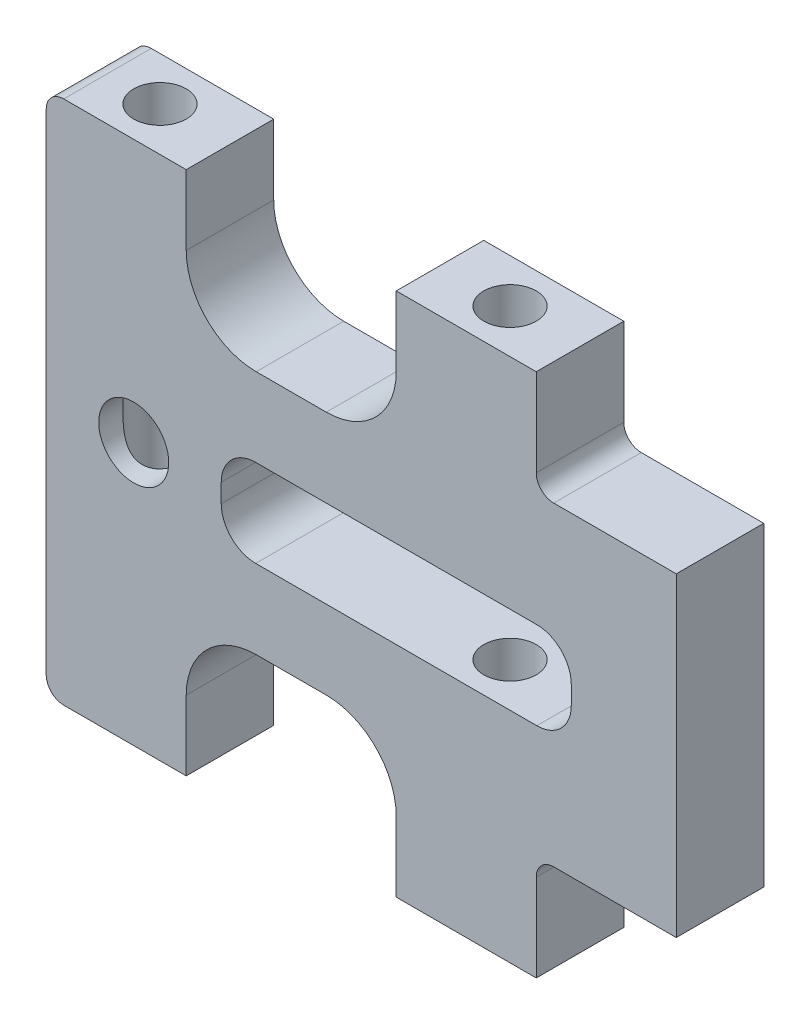
from build123d import *

# Parameters (mm, degrees)
SKETCH1_R           = 2
BOSS_EXTRUDE1_DEPTH = 5
SKETCH2_R           = 1.5
CUT_EXTRUDE1_DEPTH  = 31
CUT_EXTRUDE2_DEPTH  = 6.0000001


with BuildPart() as part:
    # Sketch1 → Boss-Extrude1 (new body)
    with BuildSketch(Plane.XY):
        with BuildLine():
            Line((1, 0), (35, 0))
            ThreePointArc((35, 0), (35.707106781, 0.292893219), (36, 1))
            Line((36, 1), (36, 29))
            ThreePointArc((36, 29), (35.707106781, 29.707106781), (35, 30))
            Line((35, 30), (1, 30))
            ThreePointArc((1, 30), (0.292893219, 29.707106781), (0, 29))
            Line((0, 29), (0, 7))
            Line((0, 7), (0, 1))
            ThreePointArc((0, 1), (0.292893219, 0.292893219), (1, 0))
        make_face()
        with Locations((5, 15)):
            Circle(SKETCH1_R, mode=Mode.SUBTRACT)
        with BuildLine():
            Line((11.967452223, 12.5), (28.032547777, 12.5))
            ThreePointArc((28.032547777, 12.5), (29.423746586, 13.076253414), (30, 14.467452223))
            Line((30, 14.467452223), (30, 15.532547777))
            ThreePointArc((30, 15.532547777), (29.423746586, 16.923746586), (28.032547777, 17.5))
            Line((28.032547777, 17.5), (11.967452223, 17.5))
            ThreePointArc((11.967452223, 17.5), (10.576253414, 16.923746586), (10, 15.532547777))
            Line((10, 15.532547777), (10, 14.467452223))
            ThreePointArc((10, 14.467452223), (10.576253414, 13.076253414), (11.967452223, 12.5))
        make_face(mode=Mode.SUBTRACT)
    extrude(amount=BOSS_EXTRUDE1_DEPTH)

    # Sketch2 → Cut-Extrude1 (cut, through all)
    with BuildSketch(Plane(origin=(0, 30, 0), x_dir=(1, 0, 0), z_dir=(0, 1, 0))):
        with Locations((4, -2.5)):
            Circle(SKETCH2_R)
        with Locations((24, -2.5)):
            Circle(SKETCH2_R)
    extrude(amount=-CUT_EXTRUDE1_DEPTH, mode=Mode.SUBTRACT)

    # Sketch3 → Cut-Extrude2 (cut, through all)
    with BuildSketch(Plane.XY.offset(5)):
        with BuildLine():
            Line((28, 30), (28, 25))
            ThreePointArc((28, 25), (28.292893219, 24.292893219), (29, 24))
            Line((29, 24), (43, 24))
            ThreePointArc((43, 24), (43.707106781, 23.707106781), (44, 23))
            Line((44, 23), (44, 7))
            ThreePointArc((44, 7), (43.707106781, 6.292893219), (43, 6))
            Line((43, 6), (29, 6))
            ThreePointArc((29, 6), (28.292893219, 5.707106781), (28, 5))
            Line((28, 5), (28, 0))
            Line((28, 0), (56.755309453, 0))
            Line((56.755309453, 0), (56.755309453, 30))
            Line((56.755309453, 30), (28, 30))
        make_face()
        with BuildLine():
            Line((8, 30), (8, 26))
            ThreePointArc((8, 26), (9.171572875, 23.171572875), (12, 22))
            Line((12, 22), (16, 22))
            ThreePointArc((16, 22), (18.828427125, 23.171572875), (20, 26))
            Line((20, 26), (20, 30))
            Line((20, 30), (8, 30))
        make_face()
        with BuildLine():
            Line((8, 0), (8, 4))
            ThreePointArc((8, 4), (9.171572875, 6.828427125), (12, 8))
            Line((12, 8), (16, 8))
            ThreePointArc((16, 8), (18.828427125, 6.828427125), (20, 4))
            Line((20, 4), (20, 0))
            Line((20, 0), (8, 0))
        make_face()
    extrude(amount=-CUT_EXTRUDE2_DEPTH, mode=Mode.SUBTRACT)


solid = part.part
